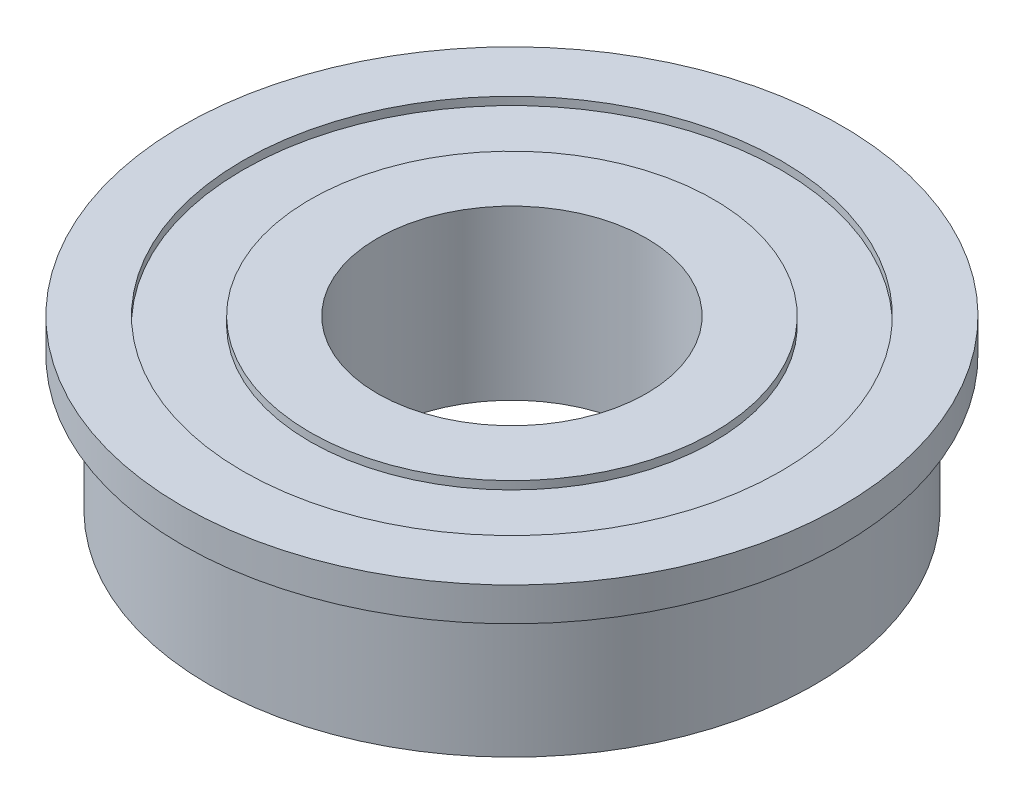
from build123d import *


with BuildPart() as part:
    # Sketch1 → Revolve1 (revolve)
    with BuildSketch(Plane(origin=(0, 0, 0), x_dir=(-1, 0, 0), z_dir=(0, 0, -1))):
        Polygon((-9.525, 7.5565), (-12.7, 7.5565), (-12.7, 7.9375), (-15.5575, 7.9375), (-15.5575, 6.35), (-14.2875, 6.35), (-14.2875, 0), (-6.35, 0), (-6.35, 7.9375), (-9.525, 7.9375), align=None)
    revolve(axis=Axis((0, 0, 0), (0, 1, 0)))


solid = part.part
